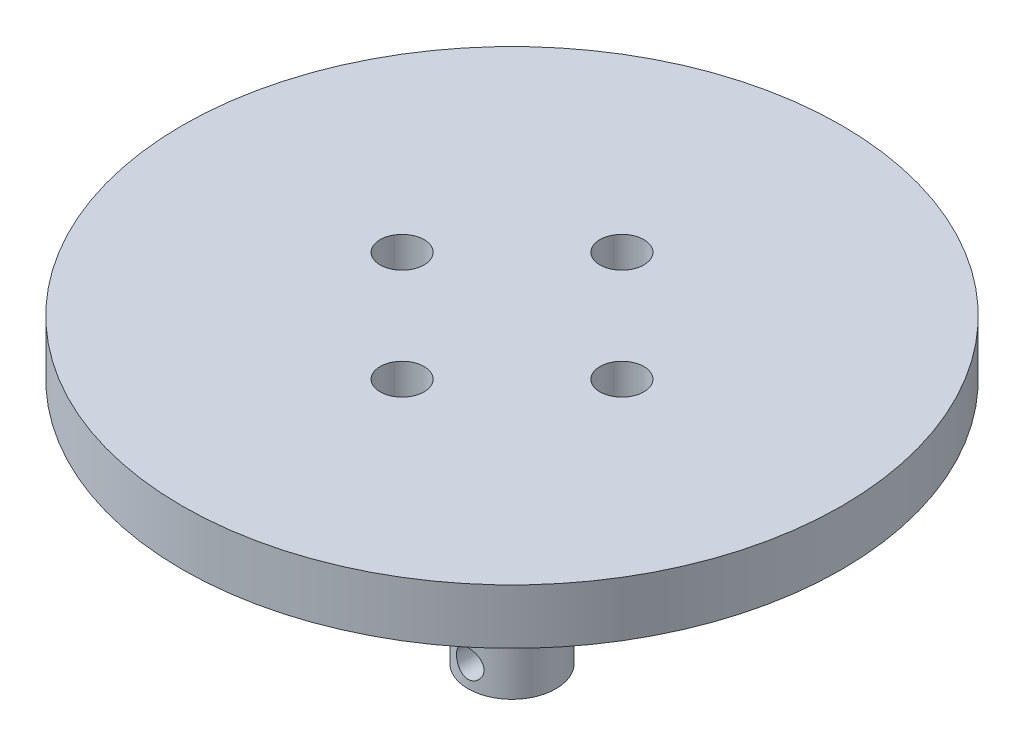
from build123d import *

# Parameters (mm, degrees)
CROQUIS1_R              = 4
CROQUIS1_R_2            = 2.05
SALIENTE_EXTRUIR1_DEPTH = 25.4
CROQUIS2_R              = 30
SALIENTE_EXTRUIR2_DEPTH = 5
CROQUIS3_R              = 2
CORTAR_EXTRUIR1_DEPTH   = 7.5
CROQUIS7_R              = 3.5
CORTAR_EXTRUIR3_DEPTH   = 3
CROQUIS8_W              = 62.698346187
CROQUIS8_H              = 3
CORTAR_EXTRUIR5_DEPTH   = 15
CROQUIS1_3_R            = 2.05
CORTAR_EXTRUIR6_DEPTH   = 7.4
SALIENTE_EXTRUIR3_DEPTH = 10
CROQUIS6_R              = 1.25
CORTAR_EXTRUIR7_DEPTH   = 10


with BuildPart() as part:
    # Croquis1 → Saliente-Extruir1 (new body)
    with BuildSketch(Plane(origin=(0, 0, 0), x_dir=(1, 0, 0), z_dir=(0, 1, 0))):
        with Locations(Location((0, 0, 0), (0, 0, 270))):
            Circle(CROQUIS1_R)
        Circle(CROQUIS1_R_2, mode=Mode.SUBTRACT)
        Circle(CROQUIS1_R_2)
    extrude(amount=SALIENTE_EXTRUIR1_DEPTH)

    # Croquis2 → Saliente-Extruir2 (add)
    with BuildSketch(Plane(origin=(0, 25.4, 0), x_dir=(1, 0, 0), z_dir=(0, 1, 0))):
        with Locations(Location((0, 0, 0), (0, 0, 270))):
            Circle(CROQUIS2_R)
    extrude(amount=SALIENTE_EXTRUIR2_DEPTH)

    # Croquis3 → Cortar-Extruir1 (cut)
    with BuildSketch(Plane(origin=(0, 30.4, 0), x_dir=(1, 0, 0), z_dir=(0, 1, 0))):
        with Locations(Location((0, 10, 0), (0, 0, 270))):
            Circle(CROQUIS3_R)
        with Locations(Location((10, 0, 0), (0, 0, 270))):
            Circle(CROQUIS3_R)
        with Locations(Location((0, -10, 0), (0, 0, 270))):
            Circle(CROQUIS3_R)
        with Locations(Location((-10, 0, 0), (0, 0, 270))):
            Circle(CROQUIS3_R)
    extrude(amount=-CORTAR_EXTRUIR1_DEPTH, mode=Mode.SUBTRACT)

    # Croquis7 → Cortar-Extruir3 (cut)
    with BuildSketch(Plane.XZ):
        with Locations(Location((0, 0, 0), (0, 0, 270))):
            Circle(CROQUIS7_R)
    extrude(amount=-CORTAR_EXTRUIR3_DEPTH, mode=Mode.SUBTRACT)

    # Croquis8 → Cortar-Extruir5 (cut, symmetric)
    with BuildSketch(Plane(origin=(0, 0, 0), x_dir=(0, 0, -1), z_dir=(1, 0, 0))):
        with Locations((4.276742622, 1.5)):
            Rectangle(CROQUIS8_W, CROQUIS8_H)
    extrude(amount=CORTAR_EXTRUIR5_DEPTH, both=True, mode=Mode.SUBTRACT)

    # Croquis1_3 → Cortar-Extruir6 (cut)
    with BuildSketch(Plane(origin=(0, 0, 0), x_dir=(1, 0, 0), z_dir=(0, 1, 0))):
        with Locations(Location((0, 0, 0), (0, 0, 90))):
            Circle(CROQUIS1_3_R)
    extrude(amount=CORTAR_EXTRUIR6_DEPTH, mode=Mode.SUBTRACT)

    # Croquis9 → Saliente-Extruir3 (add)
    with BuildSketch(Plane.XZ.offset(-3)):
        with BuildLine():
            ThreePointArc((1.281600562, 1.6), (0, 2.05), (-1.281600562, 1.6))
            Line((-1.281600562, 1.6), (1.281600562, 1.6))
        make_face()
    extrude(amount=-SALIENTE_EXTRUIR3_DEPTH)

    # Croquis6 → Cortar-Extruir7 (cut)
    with BuildSketch(Plane.XY):
        with Locations(Location((0, 5, 0), (0, 0, 180))):
            Circle(CROQUIS6_R)
    extrude(amount=CORTAR_EXTRUIR7_DEPTH, mode=Mode.SUBTRACT)


solid = part.part
